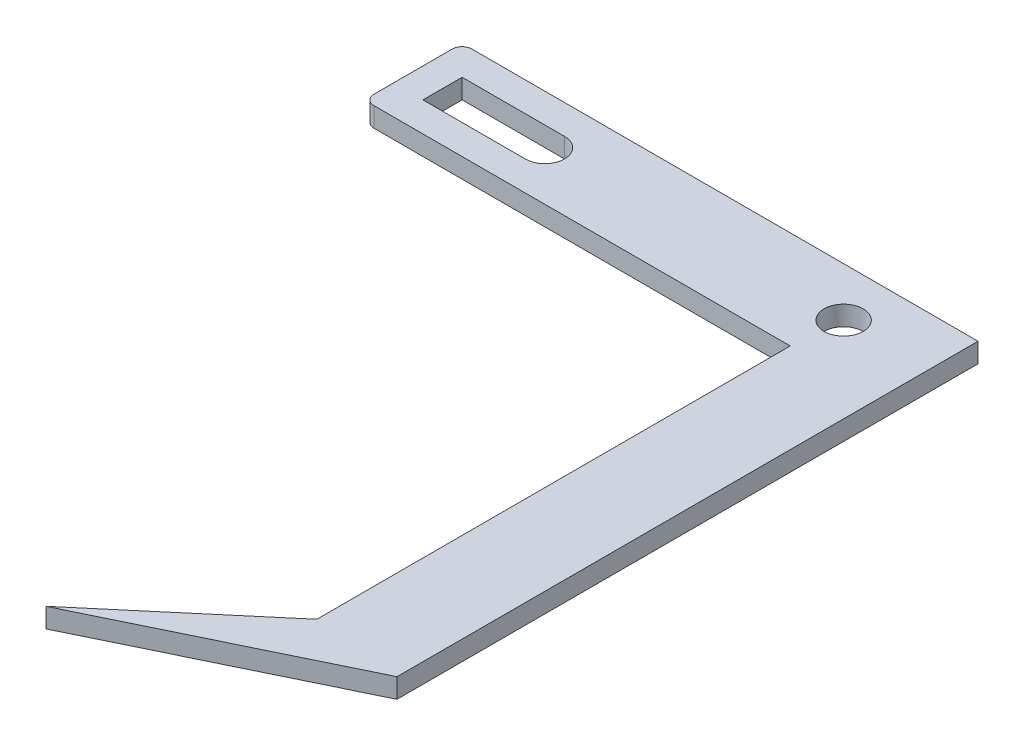
from build123d import *

# Parameters (mm, degrees)
SKETCH1_R           = 2
BOSS_EXTRUDE2_DEPTH = 2
CUT_EXTRUDE2_DEPTH  = 9
CUT_EXTRUDE3_DEPTH  = 9
CUT_EXTRUDE4_DEPTH  = 10
CUT_EXTRUDE5_DEPTH  = 10
CUT_EXTRUDE6_DEPTH  = 10
CUT_EXTRUDE8_DEPTH  = 20


with BuildPart() as part:
    # Sketch1 → Boss-Extrude2 (new body)
    with BuildSketch(Plane(origin=(0, 0, 0), x_dir=(1, 0, 0), z_dir=(0, 1, 0))):
        with BuildLine():
            Line((0, 48.412862342), (0, 37.692030173))
            ThreePointArc((0, 37.692030173), (0.292893219, 36.984923392), (1, 36.692030173))
            Line((1, 36.692030173), (31.48, 36.692030173))
            Line((31.48, 36.692030173), (43.036527631, 36.692030173))
            Line((43.036527631, 36.692030173), (43.036527631, -13.307969827))
            Line((43.036527631, -13.307969827), (38.310297741, -17.310739702))
            Line((38.310297741, -17.310739702), (34.253582629, -17.310739702))
            Line((34.253582629, -17.310739702), (36, -19.267392345))
            Line((36, -19.267392345), (30.071702425, -24.288225334))
            Line((30.071702425, -24.288225334), (54.200832168, -12.602889922))
            Line((54.200832168, -12.602889922), (54.200832168, 10.267562985))
            Line((54.200832168, 10.267562985), (54.200832168, 49.412862342))
            Line((54.200832168, 49.412862342), (41.48, 49.412862342))
            Line((41.48, 49.412862342), (1, 49.412862342))
            ThreePointArc((1, 49.412862342), (0.292893219, 49.119969123), (0, 48.412862342))
        make_face()
        with Locations((45.48, 41.700609081)):
            Circle(SKETCH1_R, mode=Mode.SUBTRACT)
        with BuildLine():
            Line((15, 43.700609081), (4.549516448, 43.700609081))
            Line((4.549516448, 43.700609081), (4.549516448, 39.700609081))
            Line((4.549516448, 39.700609081), (15, 39.700609081))
            ThreePointArc((15, 39.700609081), (17, 41.700609081), (15, 43.700609081))
        make_face(mode=Mode.SUBTRACT)
    extrude(amount=BOSS_EXTRUDE2_DEPTH)

    # Sketch6 → Cut-Extrude2 (cut)
    with BuildSketch(Plane(origin=(0, 2, 0), x_dir=(1, 0, 0), z_dir=(0, 1, 0))):
        Polygon((36, -19.267392345), (38.310297741, -17.310739702), (34.253582629, -17.310739702), align=None)
    extrude(amount=-CUT_EXTRUDE2_DEPTH, mode=Mode.SUBTRACT)

    # Sketch8 → Cut-Extrude3 (cut)
    with BuildSketch(Plane(origin=(0, 2, 0), x_dir=(1, 0, 0), z_dir=(0, 1, 0))):
        Polygon((43.036527631, 36.692030173), (45.036527631, 36.692030173), (45.036527631, -11.115496155), (45.036527631, -11.614116599), (43.036527631, -13.307969827), align=None)
    extrude(amount=-CUT_EXTRUDE3_DEPTH, mode=Mode.SUBTRACT)

    # Sketch9 → Cut-Extrude4 (cut)
    with BuildSketch(Plane(origin=(0, 2, 0), x_dir=(1, 0, 0), z_dir=(0, 1, 0))):
        with BuildLine():
            Line((0, 46.692030173), (54.200832168, 46.692030173))
            Line((54.200832168, 46.692030173), (54.200832168, 49.412862342))
            Line((54.200832168, 49.412862342), (1, 49.412862342))
            ThreePointArc((1, 49.412862342), (0.292893219, 49.119969123), (0, 48.412862342))
            Line((0, 48.412862342), (0, 46.692030173))
        make_face()
    extrude(amount=-CUT_EXTRUDE4_DEPTH, mode=Mode.SUBTRACT)

    # Sketch11 → Cut-Extrude5 (cut)
    with BuildSketch(Plane(origin=(0, 2, 0), x_dir=(1, 0, 0), z_dir=(0, 1, 0))):
        with BuildLine():
            Line((1, 46.692030173), (0, 46.692030173))
            Line((0, 46.692030173), (0, 45.692030173))
            ThreePointArc((0, 45.692030173), (0.292893219, 46.399136955), (1, 46.692030173))
        make_face()
    extrude(amount=-CUT_EXTRUDE5_DEPTH, mode=Mode.SUBTRACT)

    # Sketch12 → Cut-Extrude6 (cut)
    with BuildSketch(Plane(origin=(0, 2, 0), x_dir=(1, 0, 0), z_dir=(0, 1, 0))):
        with BuildLine():
            Line((1.549516448, 36.692030173), (1.549516448, 41.700609081))
            Line((1.549516448, 41.700609081), (1.549516448, 46.692030173))
            Line((1.549516448, 46.692030173), (1, 46.692030173))
            ThreePointArc((1, 46.692030173), (0.292893219, 46.399136955), (0, 45.692030173))
            Line((0, 45.692030173), (0, 37.692030173))
            ThreePointArc((0, 37.692030173), (0.292893219, 36.984923392), (1, 36.692030173))
            Line((1, 36.692030173), (1.549516448, 36.692030173))
        make_face()
    extrude(amount=-CUT_EXTRUDE6_DEPTH, mode=Mode.SUBTRACT)

    # Sketch13 → Cut-Extrude8 (cut)
    with BuildSketch(Plane(origin=(0, 2, 0), x_dir=(1, 0, 0), z_dir=(0, 1, 0))):
        with BuildLine():
            ThreePointArc((2.549516448, 36.692030173), (1.842409666, 36.984923392), (1.549516448, 37.692030173))
            Line((1.549516448, 37.692030173), (1.549516448, 36.692030173))
            Line((1.549516448, 36.692030173), (2.549516448, 36.692030173))
        make_face()
        with BuildLine():
            Line((2.549516448, 46.692030173), (1.549516448, 46.692030173))
            Line((1.549516448, 46.692030173), (1.549516448, 45.692030173))
            ThreePointArc((1.549516448, 45.692030173), (1.842409666, 46.399136955), (2.549516448, 46.692030173))
        make_face()
    extrude(amount=-CUT_EXTRUDE8_DEPTH, mode=Mode.SUBTRACT)


solid = part.part
